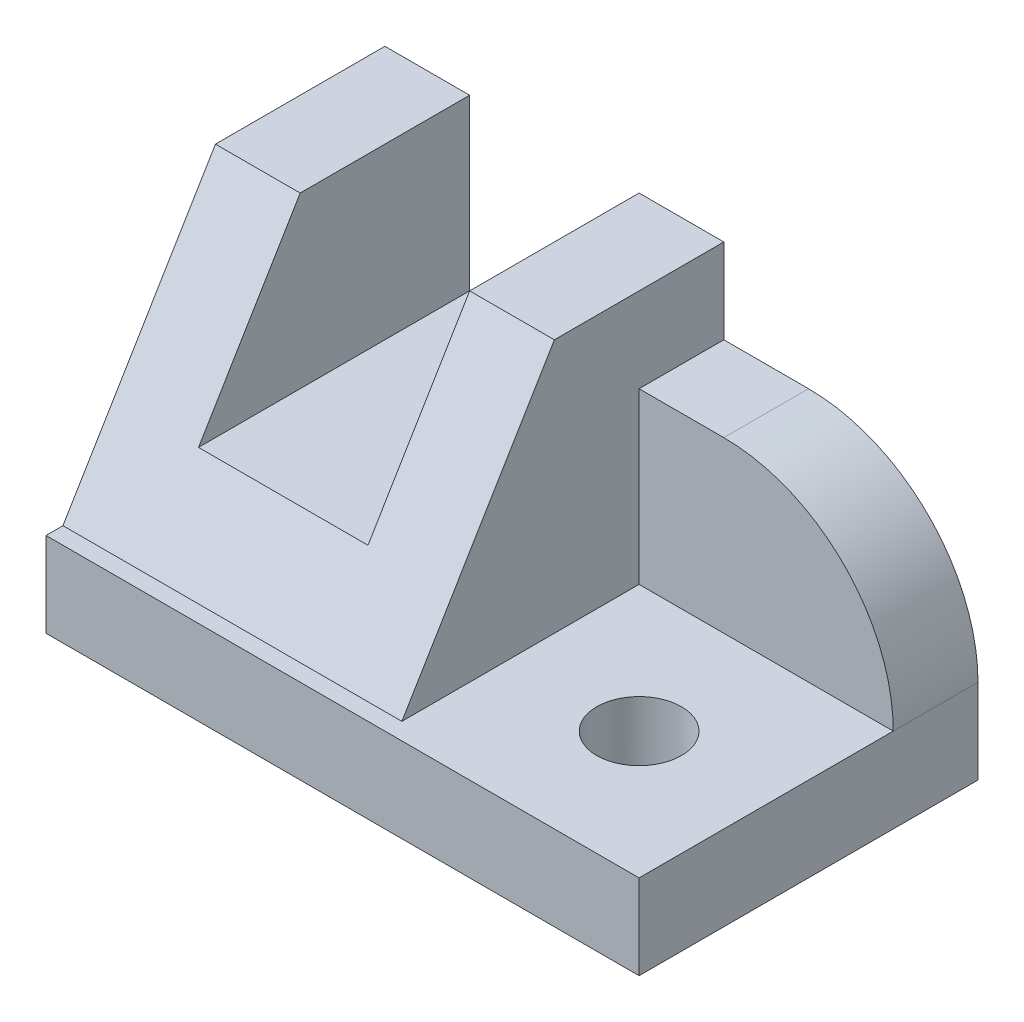
from build123d import *

# Parameters (mm, degrees)
BOSS_EXTRUDE1_DEPTH            = 40
SKETCH2_W                      = 40
SKETCH2_H                      = 30
BOSS_EXTRUDE2_DEPTH            = 20
BOSS_EXTRUDE3_DEPTH            = 30
CUT_EXTRUDE1_DEPTH             = 30
SKETCH5_W                      = 70
SKETCH5_H                      = 40
BOSS_EXTRUDE4_DEPTH            = 10
SKETCH6_W                      = 20
SKETCH6_H                      = 20
CUT_EXTRUDE2_DEPTH             = 41
F_10_0_10_DIAMETER_HOLE1_D     = 10
F_10_0_10_DIAMETER_HOLE1_DEPTH = 40
FILLET1_R                      = 20


with BuildPart() as part:
    # Sketch1 → Boss-Extrude1 (new body)
    with BuildSketch(Plane(origin=(0, 0, 0), x_dir=(0, -1, 0), z_dir=(-1, 0, 0))):
        Polygon((-10, -2), (-40, -20), (-10, -20), align=None)
    extrude(amount=-BOSS_EXTRUDE1_DEPTH)

    # Sketch2 → Boss-Extrude2 (add)
    with BuildSketch(Plane(origin=(0, 0, -20), x_dir=(-1, 0, 0), z_dir=(0, 0, -1))):
        with Locations((-20, 25)):
            Rectangle(SKETCH2_W, SKETCH2_H)
    extrude(amount=BOSS_EXTRUDE2_DEPTH)

    # Sketch3 → Boss-Extrude3 (add)
    with BuildSketch(Plane(origin=(40, 0, 0), x_dir=(0, 0, -1), z_dir=(1, 0, 0))):
        Polygon((40, 10), (0, 10), (20, 40), (40, 40), align=None)
    extrude(amount=BOSS_EXTRUDE3_DEPTH)

    # Sketch4 → Cut-Extrude1 (cut)
    with BuildSketch(Plane(origin=(70, 0, 0), x_dir=(0, 0, -1), z_dir=(1, 0, 0))):
        Polygon((20, 40), (0, 10), (30, 10), (30, 30), (40, 30), (40, 40), align=None)
    extrude(amount=-CUT_EXTRUDE1_DEPTH, mode=Mode.SUBTRACT)

    # Sketch5 → Boss-Extrude4 (add)
    with BuildSketch(Plane.XZ.offset(-10)):
        with Locations((35, -20)):
            Rectangle(SKETCH5_W, SKETCH5_H)
    extrude(amount=BOSS_EXTRUDE4_DEPTH)

    # Sketch6 → Cut-Extrude2 (cut, through all)
    with BuildSketch(Plane(origin=(0, 0, -40), x_dir=(-1, 0, 0), z_dir=(0, 0, -1))):
        with Locations((-20, 30)):
            Rectangle(SKETCH6_W, SKETCH6_H)
    extrude(amount=-CUT_EXTRUDE2_DEPTH, mode=Mode.SUBTRACT)

    # Ø10.0 (10) Diameter Hole1
    with Locations(Plane(origin=(0, 0, 0), x_dir=(-1, 0, 0), z_dir=(0, -1, 0))):
        with Locations((-55, 15)):
            Hole(F_10_0_10_DIAMETER_HOLE1_D / 2, depth=F_10_0_10_DIAMETER_HOLE1_DEPTH)

    # Fillet1
    fillet1_edges = [part.edges().sort_by_distance(p)[0] for p in [
        (70, 30, -35),
    ]]
    fillet(fillet1_edges, radius=FILLET1_R)


solid = part.part
